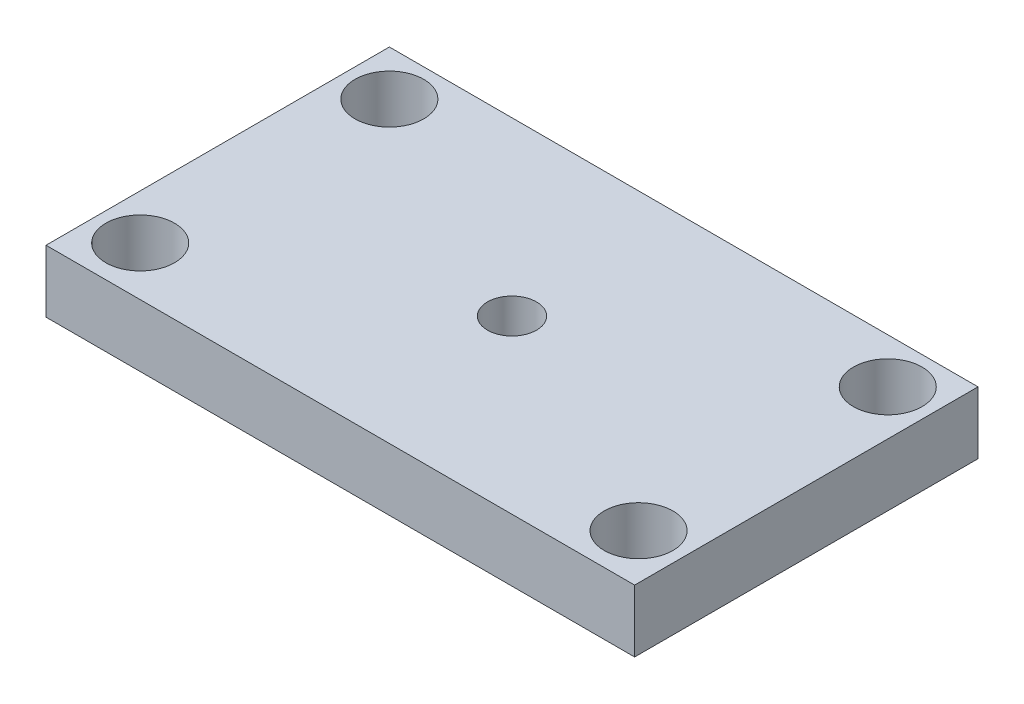
from build123d import *

# Parameters (mm, degrees)
SKETCH1_W           = 60
SKETCH1_H           = 35
SKETCH1_R           = 3.5
SKETCH1_R_2         = 2.5
BOSS_EXTRUDE1_DEPTH = 6.35


with BuildPart() as part:
    # Sketch1 → Boss-Extrude1 (new body)
    with BuildSketch(Plane(origin=(0, 0, 0), x_dir=(1, 0, 0), z_dir=(0, 1, 0))):
        with Locations((30, 17.5)):
            Rectangle(SKETCH1_W, SKETCH1_H)
        with Locations((4.6, 30.4)):
            Circle(SKETCH1_R, mode=Mode.SUBTRACT)
        with Locations((55.4, 30.4)):
            Circle(SKETCH1_R, mode=Mode.SUBTRACT)
        with Locations((4.6, 5)):
            Circle(SKETCH1_R, mode=Mode.SUBTRACT)
        with Locations((55.4, 5)):
            Circle(SKETCH1_R, mode=Mode.SUBTRACT)
        with Locations((30, 17.5)):
            Circle(SKETCH1_R_2, mode=Mode.SUBTRACT)
    extrude(amount=BOSS_EXTRUDE1_DEPTH)


solid = part.part
